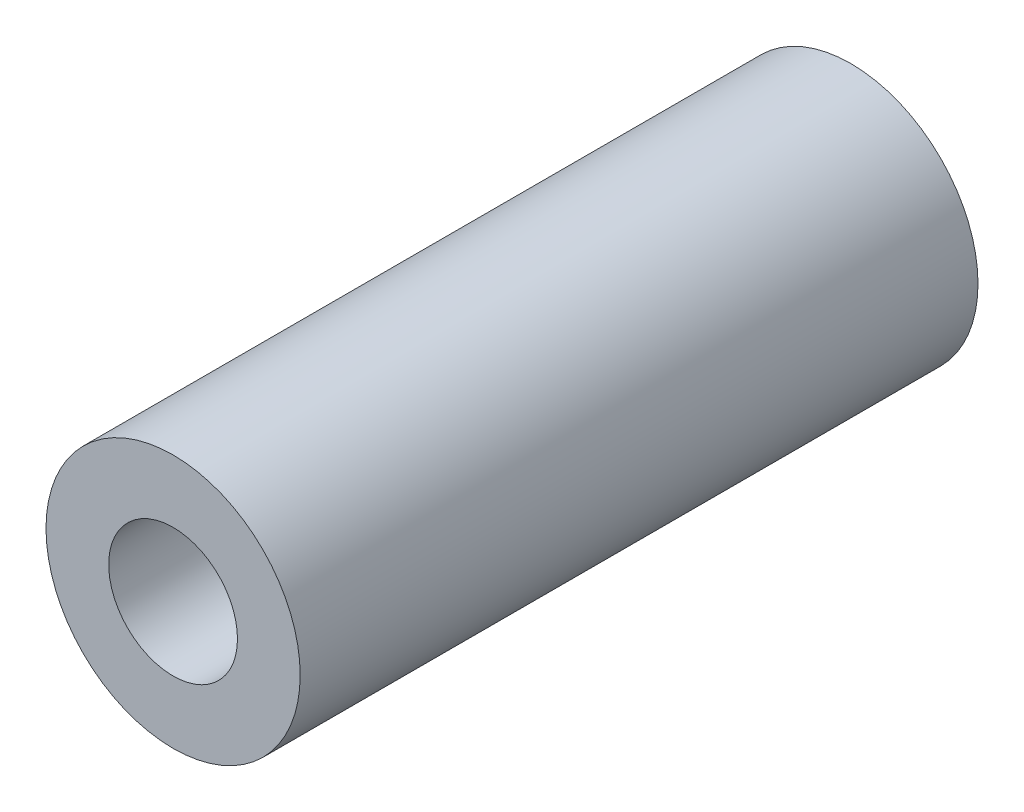
from build123d import *

# Parameters (mm, degrees)
SKETCH1_R      = 9.525
SKETCH1_R_2    = 4.826
EXTRUDE1_DEPTH = 25.4


with BuildPart() as part:
    # Sketch1 → Extrude1 (new body, symmetric)
    with BuildSketch(Plane.XY):
        Circle(SKETCH1_R)
        Circle(SKETCH1_R_2, mode=Mode.SUBTRACT)
    extrude(amount=EXTRUDE1_DEPTH, both=True)


solid = part.part
